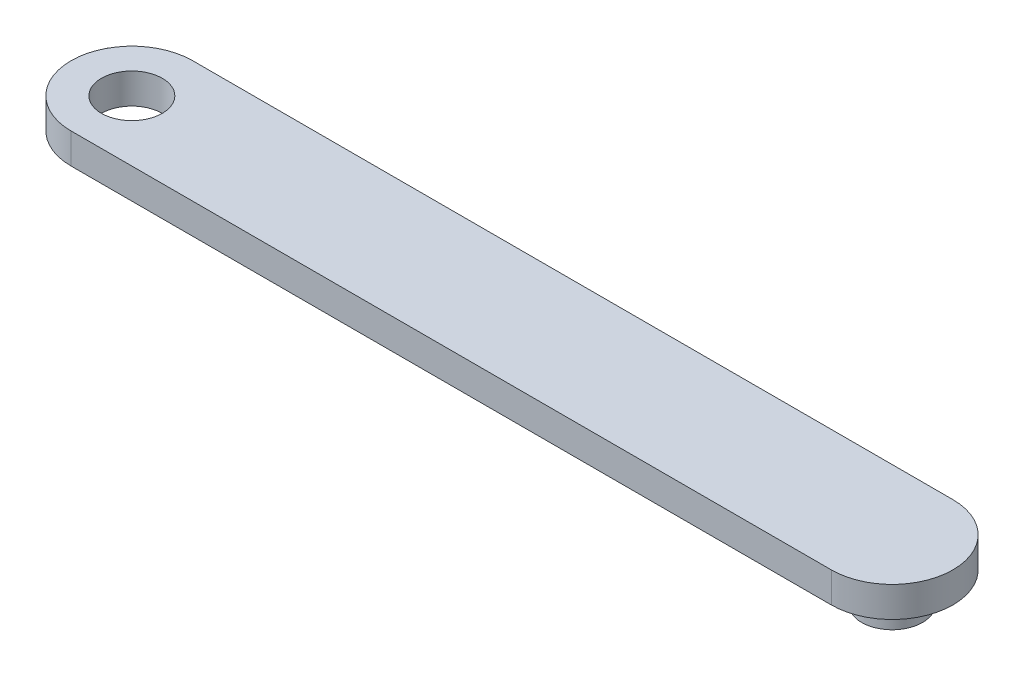
from build123d import *

# Parameters (mm, degrees)
SKETCH1_R           = 1
BOSS_EXTRUDE2_DEPTH = 1
SKETCH5_R           = 1
BOSS_EXTRUDE3_DEPTH = 1


with BuildPart() as part:
    # Sketch1 → Boss-Extrude2 (new body)
    with BuildSketch(Plane(origin=(0, 0, 0), x_dir=(1, 0, 0), z_dir=(0, 1, 0))):
        with BuildLine():
            Line((-12.5, 2), (12.5, 2))
            ThreePointArc((12.5, 2), (14.5, 0), (12.5, -2))
            Line((12.5, -2), (-12.5, -2))
            ThreePointArc((-12.5, -2), (-14.5, 0), (-12.5, 2))
        make_face()
        with Locations((-12.5, 0)):
            Circle(SKETCH1_R, mode=Mode.SUBTRACT)
    extrude(amount=BOSS_EXTRUDE2_DEPTH)

    # Sketch5 → Boss-Extrude3 (add)
    with BuildSketch(Plane.XZ):
        with Locations((12.5, 0)):
            Circle(SKETCH5_R)
    extrude(amount=BOSS_EXTRUDE3_DEPTH)


solid = part.part
